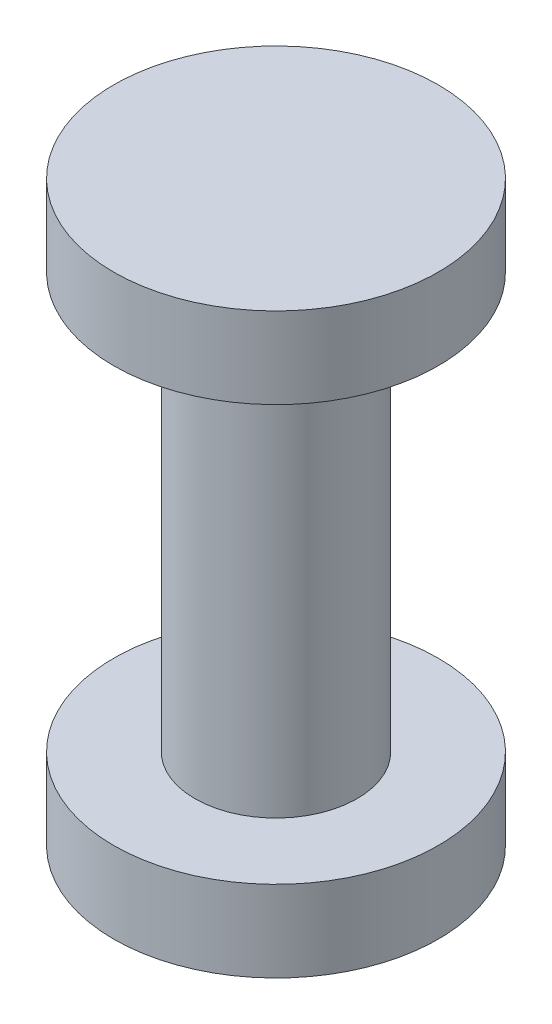
from build123d import *

# Parameters (mm, degrees)
SKETCH1_R           = 2.5
BOSS_EXTRUDE1_DEPTH = 12.8
SKETCH2_R           = 5
BOSS_EXTRUDE2_DEPTH = 2.5
SKETCH3_R           = 5
BOSS_EXTRUDE3_DEPTH = 2.5


with BuildPart() as part:
    # Sketch1 → Boss-Extrude1 (new body)
    with BuildSketch(Plane(origin=(0, 0, 0), x_dir=(1, 0, 0), z_dir=(0, 1, 0))):
        Circle(SKETCH1_R)
    extrude(amount=BOSS_EXTRUDE1_DEPTH)

    # Sketch2 → Boss-Extrude2 (add)
    with BuildSketch(Plane(origin=(0, 12.8, 0), x_dir=(1, 0, 0), z_dir=(0, 1, 0))):
        Circle(SKETCH2_R)
    extrude(amount=BOSS_EXTRUDE2_DEPTH)

    # Sketch3 → Boss-Extrude3 (add)
    with BuildSketch(Plane(origin=(0, 0, 0), x_dir=(-1, 0, 0), z_dir=(0, -1, 0))):
        Circle(SKETCH3_R)
    extrude(amount=BOSS_EXTRUDE3_DEPTH)


solid = part.part
